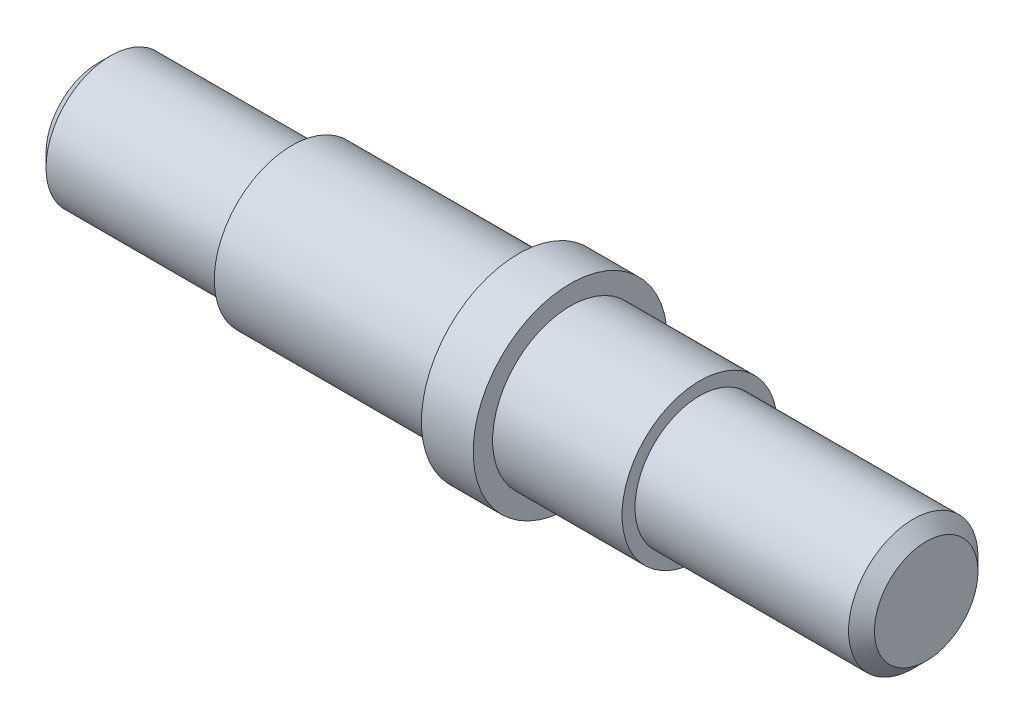
from build123d import *

# Parameters (mm, degrees)
ZKOSEN_1_SIZE = 2


with BuildPart() as part:
    # Skica1 → Rotovat1 (revolve)
    with BuildSketch(Plane.XY):
        Polygon((0, 0), (0, 10), (30, 10), (30, 12), (65, 12), (65, 15), (73, 15), (73, 12), (93, 12), (93, 10), (128, 10), (128, 0), align=None)
    revolve(axis=Axis((128, 0, 0), (-1, 0, 0)))

    # Zkosení1
    zkosen_1_edges = [part.edges().sort_by_distance(p)[0] for p in [
        (0, -10, 0),
        (128, -10, 0),
    ]]
    chamfer(zkosen_1_edges, length=ZKOSEN_1_SIZE)


solid = part.part
